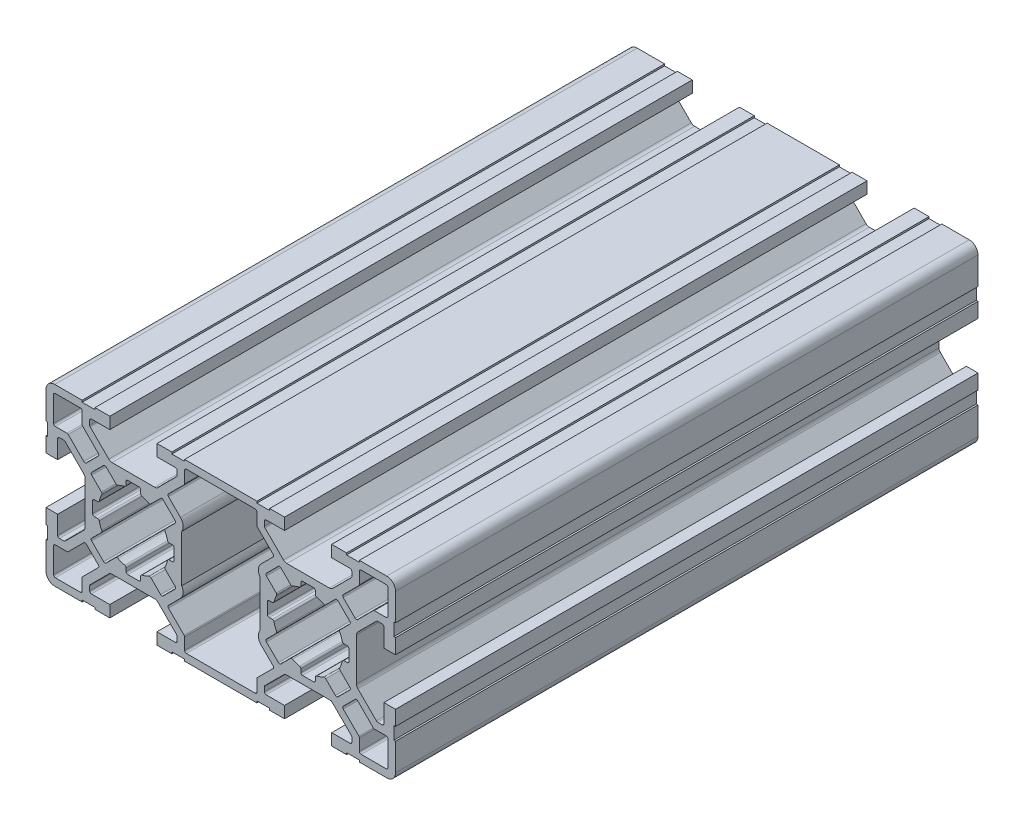
from build123d import *

# Parameters (mm, degrees)
RETANGULAR_PF30_02_PERFIL_3060_B_SICO_DEPTH = 100


with BuildPart() as part:
    # Sketch1 → Retangular PF30-02 - PERFIL 3060 BÁSICO(1) (new body)
    with BuildSketch(Plane(origin=(0, 0, 50), x_dir=(0, -1, 0), z_dir=(0, 0, -1))):
        with BuildLine():
            Line((-4.049998685, 29.999996087), (-4.049998685, 27.999995534))
            Line((-4.049998685, 27.999995534), (-7.199996435, 27.999995648))
            ThreePointArc((-7.199996435, 27.999995648), (-7.412128477, 27.912127686), (-7.499996446, 27.699995648))
            Line((-7.499996446, 27.699995648), (-7.499996446, 26.937612154))
            ThreePointArc((-7.499996446, 26.937612154), (-7.477160306, 26.822807125), (-7.412128481, 26.72548012))
            Line((-7.412128481, 26.72548012), (-4.22098228, 23.53433392))
            ThreePointArc((-4.22098228, 23.53433392), (-3.961443601, 23.360915719), (-3.655296856, 23.300019345))
            Line((-3.655296856, 23.300019345), (3.655296879, 23.300019345))
            ThreePointArc((3.655296879, 23.300019345), (3.961443625, 23.360915719), (4.220982304, 23.53433392))
            Line((4.220982304, 23.53433392), (7.412128505, 26.72548012))
            ThreePointArc((7.412128505, 26.72548012), (7.47716033, 26.822807125), (7.49999647, 26.937612154))
            Line((7.49999647, 26.937612154), (7.49999647, 27.699995534))
            ThreePointArc((7.49999647, 27.699995534), (7.412128505, 27.912127568), (7.19999647, 27.999995534))
            Line((7.19999647, 27.999995534), (4.05, 27.999995534))
            Line((4.05, 27.999995534), (4.05, 29.999996185))
            Line((4.05, 29.999996185), (6.599996803, 29.999996185))
            Line((6.599996803, 29.999996185), (6.599996803, 29.699996185))
            Line((6.599996803, 29.699996185), (8.799996803, 29.699996185))
            Line((8.799996803, 29.699996185), (8.799996803, 29.999996087))
            Line((8.799996803, 29.999996087), (13.499995923, 29.999996087))
            ThreePointArc((13.499995923, 29.999996087), (14.560656066, 29.560656231), (14.999995923, 28.499996087))
            Line((14.999995923, 28.499996087), (14.999995923, 23.799996967))
            Line((14.999995923, 23.799996967), (14.699995923, 23.799996967))
            Line((14.699995923, 23.799996967), (14.699995923, 21.599996967))
            Line((14.699995923, 21.599996967), (14.999995923, 21.599996967))
            Line((14.999995923, 21.599996967), (14.999995923, 19.04999885))
            Line((14.999995923, 19.04999885), (12.999995369, 19.04999885))
            Line((12.999995369, 19.04999885), (12.999995483, 22.1999966))
            ThreePointArc((12.999995483, 22.1999966), (12.912127522, 22.412128642), (12.699995483, 22.499996611))
            Line((12.699995483, 22.499996611), (11.93761199, 22.499996611))
            ThreePointArc((11.93761199, 22.499996611), (11.82280696, 22.477160471), (11.725479955, 22.412128645))
            Line((11.725479955, 22.412128645), (8.534333755, 19.220982445))
            ThreePointArc((8.534333755, 19.220982445), (8.360915554, 18.961443766), (8.30001918, 18.65529702))
            Line((8.30001918, 18.65529702), (8.30001918, 11.344703285))
            ThreePointArc((8.30001918, 11.344703285), (8.360915554, 11.038556539), (8.534333755, 10.77901786))
            Line((8.534333755, 10.77901786), (11.725479955, 7.58787166))
            ThreePointArc((11.725479955, 7.58787166), (11.82280696, 7.522839835), (11.93761199, 7.500003694))
            Line((11.93761199, 7.500003694), (12.699995369, 7.500003694))
            ThreePointArc((12.699995369, 7.500003694), (12.912127403, 7.58787166), (12.999995369, 7.800003694))
            Line((12.999995369, 7.800003694), (12.999995369, 10.950000165))
            Line((12.999995369, 10.950000165), (14.99999602, 10.950000165))
            Line((14.99999602, 10.950000165), (14.99999602, 8.400003362))
            Line((14.99999602, 8.400003362), (14.69999602, 8.400003362))
            Line((14.69999602, 8.400003362), (14.69999602, 6.200003362))
            Line((14.69999602, 6.200003362), (14.99999602, 6.200003362))
            Line((14.99999602, 6.200003362), (14.99999602, -6.200003033))
            Line((14.99999602, -6.200003033), (14.69999602, -6.200003033))
            Line((14.69999602, -6.200003033), (14.69999602, -8.400003033))
            Line((14.69999602, -8.400003033), (14.99999602, -8.400003033))
            Line((14.99999602, -8.400003033), (14.99999602, -10.949999835))
            Line((14.99999602, -10.949999835), (12.999995369, -10.949999835))
            Line((12.999995369, -10.949999835), (12.999995369, -7.800003365))
            ThreePointArc((12.999995369, -7.800003365), (12.912127403, -7.587871331), (12.699995369, -7.500003365))
            Line((12.699995369, -7.500003365), (11.93761199, -7.500003365))
            ThreePointArc((11.93761199, -7.500003365), (11.82280696, -7.522839505), (11.725479955, -7.587871331))
            Line((11.725479955, -7.587871331), (8.534333755, -10.779017531))
            ThreePointArc((8.534333755, -10.779017531), (8.360915554, -11.03855621), (8.30001918, -11.344702956))
            Line((8.30001918, -11.344702956), (8.30001918, -18.655296691))
            ThreePointArc((8.30001918, -18.655296691), (8.360915554, -18.961443437), (8.534333755, -19.220982116))
            Line((8.534333755, -19.220982116), (11.725479955, -22.412128316))
            ThreePointArc((11.725479955, -22.412128316), (11.82280696, -22.477160141), (11.93761199, -22.499996282))
            Line((11.93761199, -22.499996282), (12.699995483, -22.499996282))
            ThreePointArc((12.699995483, -22.499996282), (12.912127522, -22.412128312), (12.999995483, -22.199996271))
            Line((12.999995483, -22.199996271), (12.999995369, -19.04999852))
            Line((12.999995369, -19.04999852), (14.999995923, -19.04999852))
            Line((14.999995923, -19.04999852), (14.999995923, -21.599996638))
            Line((14.999995923, -21.599996638), (14.699995923, -21.599996638))
            Line((14.699995923, -21.599996638), (14.699995923, -23.799996638))
            Line((14.699995923, -23.799996638), (14.999995923, -23.799996638))
            Line((14.999995923, -23.799996638), (14.999995923, -28.499995758))
            ThreePointArc((14.999995923, -28.499995758), (14.560656066, -29.560655901), (13.499995923, -29.999995758))
            Line((13.499995923, -29.999995758), (8.799996803, -29.999995758))
            Line((8.799996803, -29.999995758), (8.799996803, -29.699995855))
            Line((8.799996803, -29.699995855), (6.599996803, -29.699995855))
            Line((6.599996803, -29.699995855), (6.599996803, -29.999995855))
            Line((6.599996803, -29.999995855), (4.05, -29.999995855))
            Line((4.05, -29.999995855), (4.05, -27.999995204))
            Line((4.05, -27.999995204), (7.19999647, -27.999995204))
            ThreePointArc((7.19999647, -27.999995204), (7.412128505, -27.912127239), (7.49999647, -27.699995204))
            Line((7.49999647, -27.699995204), (7.49999647, -26.937611825))
            ThreePointArc((7.49999647, -26.937611825), (7.47716033, -26.822806795), (7.412128505, -26.72547979))
            Line((7.412128505, -26.72547979), (4.220982304, -23.53433359))
            ThreePointArc((4.220982304, -23.53433359), (3.961443625, -23.360915389), (3.655296879, -23.300019015))
            Line((3.655296879, -23.300019015), (-3.655296856, -23.300019015))
            ThreePointArc((-3.655296856, -23.300019015), (-3.961443601, -23.360915389), (-4.22098228, -23.53433359))
            Line((-4.22098228, -23.53433359), (-7.412128481, -26.72547979))
            ThreePointArc((-7.412128481, -26.72547979), (-7.477160306, -26.822806795), (-7.499996446, -26.937611825))
            Line((-7.499996446, -26.937611825), (-7.499996446, -27.699995319))
            ThreePointArc((-7.499996446, -27.699995319), (-7.412128477, -27.912127357), (-7.199996435, -27.999995319))
            Line((-7.199996435, -27.999995319), (-4.049998685, -27.999995204))
            Line((-4.049998685, -27.999995204), (-4.049998685, -29.999995758))
            Line((-4.049998685, -29.999995758), (-6.599996803, -29.999995758))
            Line((-6.599996803, -29.999995758), (-6.599996803, -29.699995758))
            Line((-6.599996803, -29.699995758), (-8.799996803, -29.699995758))
            Line((-8.799996803, -29.699995758), (-8.799996803, -29.999995758))
            Line((-8.799996803, -29.999995758), (-13.499995923, -29.999995758))
            ThreePointArc((-13.499995923, -29.999995758), (-14.560656066, -29.560655901), (-14.999995923, -28.499995758))
            Line((-14.999995923, -28.499995758), (-14.999995923, -23.799996638))
            Line((-14.999995923, -23.799996638), (-14.699995923, -23.799996638))
            Line((-14.699995923, -23.799996638), (-14.699995923, -21.599996638))
            Line((-14.699995923, -21.599996638), (-14.999995923, -21.599996638))
            Line((-14.999995923, -21.599996638), (-14.999995923, -19.04999852))
            Line((-14.999995923, -19.04999852), (-12.999995369, -19.04999852))
            Line((-12.999995369, -19.04999852), (-12.999995483, -22.199996271))
            ThreePointArc((-12.999995483, -22.199996271), (-12.912127522, -22.412128312), (-12.699995483, -22.499996282))
            Line((-12.699995483, -22.499996282), (-11.93761199, -22.499996282))
            ThreePointArc((-11.93761199, -22.499996282), (-11.82280696, -22.477160141), (-11.725479955, -22.412128316))
            Line((-11.725479955, -22.412128316), (-8.534333755, -19.220982116))
            ThreePointArc((-8.534333755, -19.220982116), (-8.360915554, -18.961443437), (-8.30001918, -18.655296691))
            Line((-8.30001918, -18.655296691), (-8.30001918, -11.344702956))
            ThreePointArc((-8.30001918, -11.344702956), (-8.360915554, -11.03855621), (-8.534333755, -10.779017531))
            Line((-8.534333755, -10.779017531), (-11.725479955, -7.587871331))
            ThreePointArc((-11.725479955, -7.587871331), (-11.82280696, -7.522839505), (-11.93761199, -7.500003365))
            Line((-11.93761199, -7.500003365), (-12.699995369, -7.500003365))
            ThreePointArc((-12.699995369, -7.500003365), (-12.912127403, -7.587871331), (-12.999995369, -7.800003365))
            Line((-12.999995369, -7.800003365), (-12.999995369, -10.949999835))
            Line((-12.999995369, -10.949999835), (-14.99999602, -10.949999835))
            Line((-14.99999602, -10.949999835), (-14.99999602, -8.400003033))
            Line((-14.99999602, -8.400003033), (-14.69999602, -8.400003033))
            Line((-14.69999602, -8.400003033), (-14.69999602, -6.200003033))
            Line((-14.69999602, -6.200003033), (-14.99999602, -6.200003033))
            Line((-14.99999602, -6.200003033), (-14.99999602, 6.200003362))
            Line((-14.99999602, 6.200003362), (-14.69999602, 6.200003362))
            Line((-14.69999602, 6.200003362), (-14.69999602, 8.400003362))
            Line((-14.69999602, 8.400003362), (-14.99999602, 8.400003362))
            Line((-14.99999602, 8.400003362), (-14.99999602, 10.950000165))
            Line((-14.99999602, 10.950000165), (-12.999995369, 10.950000165))
            Line((-12.999995369, 10.950000165), (-12.999995369, 7.800003694))
            ThreePointArc((-12.999995369, 7.800003694), (-12.912127403, 7.58787166), (-12.699995369, 7.500003694))
            Line((-12.699995369, 7.500003694), (-11.93761199, 7.500003694))
            ThreePointArc((-11.93761199, 7.500003694), (-11.82280696, 7.522839835), (-11.725479955, 7.58787166))
            Line((-11.725479955, 7.58787166), (-8.534333755, 10.77901786))
            ThreePointArc((-8.534333755, 10.77901786), (-8.360915554, 11.038556539), (-8.30001918, 11.344703285))
            Line((-8.30001918, 11.344703285), (-8.30001918, 18.65529702))
            ThreePointArc((-8.30001918, 18.65529702), (-8.360915554, 18.961443766), (-8.534333755, 19.220982445))
            Line((-8.534333755, 19.220982445), (-11.725479955, 22.412128645))
            ThreePointArc((-11.725479955, 22.412128645), (-11.82280696, 22.477160471), (-11.93761199, 22.499996611))
            Line((-11.93761199, 22.499996611), (-12.699995483, 22.499996611))
            ThreePointArc((-12.699995483, 22.499996611), (-12.912127522, 22.412128642), (-12.999995483, 22.1999966))
            Line((-12.999995483, 22.1999966), (-12.999995369, 19.04999885))
            Line((-12.999995369, 19.04999885), (-14.999995923, 19.04999885))
            Line((-14.999995923, 19.04999885), (-14.999995923, 21.599996967))
            Line((-14.999995923, 21.599996967), (-14.699995923, 21.599996967))
            Line((-14.699995923, 21.599996967), (-14.699995923, 23.799996967))
            Line((-14.699995923, 23.799996967), (-14.999995923, 23.799996967))
            Line((-14.999995923, 23.799996967), (-14.999995923, 28.499996087))
            ThreePointArc((-14.999995923, 28.499996087), (-14.560656066, 29.560656231), (-13.499995923, 29.999996087))
            Line((-13.499995923, 29.999996087), (-8.799996803, 29.999996087))
            Line((-8.799996803, 29.999996087), (-8.799996803, 29.699996087))
            Line((-8.799996803, 29.699996087), (-6.599996803, 29.699996087))
            Line((-6.599996803, 29.699996087), (-6.599996803, 29.999996087))
            Line((-6.599996803, 29.999996087), (-4.049998685, 29.999996087))
        make_face()
        with BuildLine():
            Line((-6.025843274, -23.500716843), (-8.712128837, -26.187002406))
            ThreePointArc((-8.712128837, -26.187002406), (-8.777160662, -26.284329411), (-8.799996803, -26.399134441))
            Line((-8.799996803, -26.399134441), (-8.799996803, -28.399996053))
            ThreePointArc((-8.799996803, -28.399996053), (-8.887864768, -28.612128088), (-9.099996803, -28.699996053))
            Line((-9.099996803, -28.699996053), (-13.399996218, -28.699996053))
            ThreePointArc((-13.399996218, -28.699996053), (-13.612128252, -28.612128088), (-13.699996218, -28.399996053))
            Line((-13.699996218, -28.399996053), (-13.699996218, -24.09999627))
            ThreePointArc((-13.699996218, -24.09999627), (-13.612128251, -23.887864234), (-13.399996213, -23.79999627))
            Line((-13.399996213, -23.79999627), (-11.39913459, -23.79999627))
            ThreePointArc((-11.39913459, -23.79999627), (-11.28432956, -23.777160132), (-11.187002554, -23.712128308))
            Line((-11.187002554, -23.712128308), (-8.50071665, -21.025842489))
            ThreePointArc((-8.50071665, -21.025842489), (-8.288584582, -20.937974527), (-8.076452536, -21.025842541))
            Line((-8.076452536, -21.025842541), (-6.025843225, -23.076452792))
            ThreePointArc((-6.025843225, -23.076452792), (-5.937975293, -23.288584828), (-6.025843274, -23.500716843))
        make_face(mode=Mode.SUBTRACT)
        with BuildLine():
            Line((13.699995411, 5.900003245), (13.699995411, -5.900003245))
            ThreePointArc((13.699995411, -5.900003245), (13.612127462, -6.112135263), (13.399995459, -6.200003245))
            Line((13.399995459, -6.200003245), (11.399134078, -6.200003565))
            ThreePointArc((11.399134078, -6.200003565), (11.284329048, -6.222839703), (11.187002043, -6.287871527))
            Line((11.187002043, -6.287871527), (8.500716138, -8.974157346))
            ThreePointArc((8.500716138, -8.974157346), (8.288584071, -9.062025309), (8.076452024, -8.974157294))
            Line((8.076452024, -8.974157294), (6.025842487, -6.923546817))
            ThreePointArc((6.025842487, -6.923546817), (5.073763999, -6.46499579), (4.043474958, -6.700000009))
            Line((4.043474958, -6.700000009), (-4.043474611, -6.700000009))
            ThreePointArc((-4.043474611, -6.700000009), (-5.073763999, -6.464995655), (-6.025842825, -6.923546826))
            Line((-6.025842825, -6.923546826), (-8.076452363, -8.974157303))
            ThreePointArc((-8.076452363, -8.974157303), (-8.288584409, -9.062025317), (-8.500716477, -8.974157355))
            Line((-8.500716477, -8.974157355), (-11.187002381, -6.287871536))
            ThreePointArc((-11.187002381, -6.287871536), (-11.284329387, -6.222839712), (-11.399134417, -6.200003574))
            Line((-11.399134417, -6.200003574), (-13.399995797, -6.200003254))
            ThreePointArc((-13.399995797, -6.200003254), (-13.6121278, -6.112135271), (-13.699995749, -5.900003254))
            Line((-13.699995749, -5.900003254), (-13.699995749, 5.900003237))
            ThreePointArc((-13.699995749, 5.900003237), (-13.6121278, 6.112135254), (-13.399995797, 6.200003237))
            Line((-13.399995797, 6.200003237), (-11.399134417, 6.200003556))
            ThreePointArc((-11.399134417, 6.200003556), (-11.284329387, 6.222839695), (-11.187002381, 6.287871518))
            Line((-11.187002381, 6.287871518), (-8.500716477, 8.974157338))
            ThreePointArc((-8.500716477, 8.974157338), (-8.288584409, 9.0620253), (-8.076452363, 8.974157286))
            Line((-8.076452363, 8.974157286), (-6.025842825, 6.923546808))
            ThreePointArc((-6.025842825, 6.923546808), (-5.073763999, 6.464995638), (-4.043474611, 6.699999991))
            Line((-4.043474611, 6.699999991), (4.043474958, 6.699999991))
            ThreePointArc((4.043474958, 6.699999991), (5.073764124, 6.464995837), (6.025842695, 6.923546939))
            Line((6.025842695, 6.923546939), (8.076452232, 8.974157416))
            ThreePointArc((8.076452232, 8.974157416), (8.288584278, 9.06202543), (8.500716346, 8.974157468))
            Line((8.500716346, 8.974157468), (11.18700225, 6.287871649))
            ThreePointArc((11.18700225, 6.287871649), (11.284329256, 6.222839825), (11.399134286, 6.200003687))
            Line((11.399134286, 6.200003687), (13.399995667, 6.200003367))
            ThreePointArc((13.399995667, 6.200003367), (13.612127579, 6.112135268), (13.699995411, 5.900003245))
        make_face(mode=Mode.SUBTRACT)
        with BuildLine():
            Line((8.076452536, 21.02584287), (6.025843225, 23.076453121))
            ThreePointArc((6.025843225, 23.076453121), (5.937975293, 23.288585157), (6.025843274, 23.500717173))
            Line((6.025843274, 23.500717173), (8.712128837, 26.187002736))
            ThreePointArc((8.712128837, 26.187002736), (8.777160662, 26.284329741), (8.799996803, 26.39913477))
            Line((8.799996803, 26.39913477), (8.799996803, 28.399996383))
            ThreePointArc((8.799996803, 28.399996383), (8.887864768, 28.612128417), (9.099996803, 28.699996383))
            Line((9.099996803, 28.699996383), (13.399996218, 28.699996383))
            ThreePointArc((13.399996218, 28.699996383), (13.612128252, 28.612128417), (13.699996218, 28.399996383))
            Line((13.699996218, 28.399996383), (13.699996218, 24.0999966))
            ThreePointArc((13.699996218, 24.0999966), (13.612128251, 23.887864564), (13.399996213, 23.7999966))
            Line((13.399996213, 23.7999966), (11.39913459, 23.7999966))
            ThreePointArc((11.39913459, 23.7999966), (11.28432956, 23.777160461), (11.187002554, 23.712128638))
            Line((11.187002554, 23.712128638), (8.50071665, 21.025842818))
            ThreePointArc((8.50071665, 21.025842818), (8.288584582, 20.937974856), (8.076452536, 21.02584287))
        make_face(mode=Mode.SUBTRACT)
        with BuildLine():
            Line((-8.712128837, 26.187002736), (-6.025843274, 23.500717173))
            ThreePointArc((-6.025843274, 23.500717173), (-5.937975293, 23.288585157), (-6.025843225, 23.076453121))
            Line((-6.025843225, 23.076453121), (-8.076452536, 21.02584287))
            ThreePointArc((-8.076452536, 21.02584287), (-8.288584582, 20.937974856), (-8.50071665, 21.025842818))
            Line((-8.50071665, 21.025842818), (-11.187002554, 23.712128638))
            ThreePointArc((-11.187002554, 23.712128638), (-11.28432956, 23.777160461), (-11.39913459, 23.7999966))
            Line((-11.39913459, 23.7999966), (-13.399996213, 23.7999966))
            ThreePointArc((-13.399996213, 23.7999966), (-13.612128251, 23.887864564), (-13.699996218, 24.0999966))
            Line((-13.699996218, 24.0999966), (-13.699996218, 28.399996383))
            ThreePointArc((-13.699996218, 28.399996383), (-13.612128252, 28.612128417), (-13.399996218, 28.699996383))
            Line((-13.399996218, 28.699996383), (-9.099996803, 28.699996383))
            ThreePointArc((-9.099996803, 28.699996383), (-8.887864768, 28.612128417), (-8.799996803, 28.399996383))
            Line((-8.799996803, 28.399996383), (-8.799996803, 26.39913477))
            ThreePointArc((-8.799996803, 26.39913477), (-8.777160662, 26.284329741), (-8.712128837, 26.187002736))
        make_face(mode=Mode.SUBTRACT)
        with BuildLine():
            Line((-3.012269005, 9.512857426), (-4.68233992, 7.842786511))
            ThreePointArc((-4.68233992, 7.842786511), (-4.894471848, 7.754918817), (-5.10660394, 7.842786115))
            Line((-5.10660394, 7.842786115), (-7.157214075, 9.893395311))
            ThreePointArc((-7.157214075, 9.893395311), (-7.245082089, 10.105527359), (-7.157214124, 10.317659428))
            Line((-7.157214124, 10.317659428), (-5.487142739, 11.987730813))
            ThreePointArc((-5.487142739, 11.987730813), (-5.403317864, 12.15077611), (-5.430017698, 12.332152783))
            ThreePointArc((-5.430017698, 12.332152783), (-5.679814912, 12.916204489), (-5.86699644, 13.523228474))
            ThreePointArc((-5.86699644, 13.523228474), (-5.973488289, 13.686610043), (-6.157921876, 13.750000127))
            Line((-6.157921876, 13.750000127), (-6.700000148, 13.750000127))
            ThreePointArc((-6.700000148, 13.750000127), (-6.912132183, 13.837868093), (-7.000000148, 14.050000127))
            Line((-7.000000148, 14.050000127), (-7.000000148, 15.950000127))
            ThreePointArc((-7.000000148, 15.950000127), (-6.912132183, 16.162132162), (-6.700000148, 16.250000127))
            Line((-6.700000148, 16.250000127), (-6.157921876, 16.250000127))
            ThreePointArc((-6.157921876, 16.250000127), (-5.973488289, 16.313390212), (-5.86699644, 16.476771781))
            ThreePointArc((-5.86699644, 16.476771781), (-5.679814961, 17.083795655), (-5.430017819, 17.667847259))
            ThreePointArc((-5.430017819, 17.667847259), (-5.403317985, 17.849223932), (-5.48714286, 18.012269229))
            Line((-5.48714286, 18.012269229), (-7.157213775, 19.682340144))
            ThreePointArc((-7.157213775, 19.682340144), (-7.245081741, 19.894472144), (-7.157213823, 20.106604164))
            Line((-7.157213823, 20.106604164), (-5.106604628, 22.157214299))
            ThreePointArc((-5.106604628, 22.157214299), (-4.894472579, 22.245082314), (-4.682340511, 22.157214348))
            Line((-4.682340511, 22.157214348), (-3.012269126, 20.487142963))
            ThreePointArc((-3.012269126, 20.487142963), (-2.849223829, 20.403318088), (-2.667847156, 20.430017922))
            ThreePointArc((-2.667847156, 20.430017922), (-2.083795553, 20.679815072), (-1.47677168, 20.86699656))
            ThreePointArc((-1.47677168, 20.86699656), (-1.313390111, 20.973488409), (-1.250000026, 21.157921996))
            Line((-1.250000026, 21.157921996), (-1.250000026, 21.700000268))
            ThreePointArc((-1.250000026, 21.700000268), (-1.16213206, 21.912132303), (-0.950000026, 22.000000268))
            Line((-0.950000026, 22.000000268), (0.949999974, 22.000000268))
            ThreePointArc((0.949999974, 22.000000268), (1.162132008, 21.912132303), (1.249999974, 21.700000268))
            Line((1.249999974, 21.700000268), (1.249999974, 21.157921996))
            ThreePointArc((1.249999974, 21.157921996), (1.313390037, 20.973488339), (1.476771654, 20.866996456))
            ThreePointArc((1.476771654, 20.866996456), (2.083795477, 20.679814986), (2.667847035, 20.430017862))
            ThreePointArc((2.667847035, 20.430017862), (2.849223708, 20.403318029), (3.012269005, 20.487142904))
            Line((3.012269005, 20.487142904), (4.68234039, 22.157214289))
            ThreePointArc((4.68234039, 22.157214289), (4.894472459, 22.245082254), (5.106604507, 22.15721424))
            Line((5.106604507, 22.15721424), (7.157213703, 20.106604105))
            ThreePointArc((7.157213703, 20.106604105), (7.24508162, 19.894472084), (7.157213654, 19.682340084))
            Line((7.157213654, 19.682340084), (5.487142739, 18.01226917))
            ThreePointArc((5.487142739, 18.01226917), (5.403317864, 17.849223873), (5.430017698, 17.6678472))
            ThreePointArc((5.430017698, 17.6678472), (5.679814822, 17.083795642), (5.866996291, 16.476771818))
            ThreePointArc((5.866996291, 16.476771818), (5.97348814, 16.31339025), (6.157921727, 16.250000165))
            Line((6.157921727, 16.250000165), (6.7, 16.250000165))
            ThreePointArc((6.7, 16.250000165), (6.912132034, 16.162132199), (7, 15.950000165))
            Line((7, 15.950000165), (7, 14.050000165))
            ThreePointArc((7, 14.050000165), (6.912132034, 13.83786813), (6.7, 13.750000165))
            Line((6.7, 13.750000165), (6.157921727, 13.750000165))
            ThreePointArc((6.157921727, 13.750000165), (5.97348814, 13.68661008), (5.866996291, 13.523228511))
            ThreePointArc((5.866996291, 13.523228511), (5.679814822, 12.916204687), (5.430017698, 12.33215313))
            ThreePointArc((5.430017698, 12.33215313), (5.403317864, 12.150776457), (5.487142739, 11.98773116))
            Line((5.487142739, 11.98773116), (7.157214124, 10.317659775))
            ThreePointArc((7.157214124, 10.317659775), (7.245082263, 10.105527533), (7.157214075, 9.893395311))
            Line((7.157214075, 9.893395311), (5.10660394, 7.842786115))
            ThreePointArc((5.10660394, 7.842786115), (4.894471848, 7.754918817), (4.68233992, 7.842786511))
            Line((4.68233992, 7.842786511), (3.012269005, 9.512857426))
            ThreePointArc((3.012269005, 9.512857426), (2.849223708, 9.596682301), (2.667847035, 9.569982467))
            ThreePointArc((2.667847035, 9.569982467), (2.083795477, 9.320185343), (1.476771653, 9.133003873))
            ThreePointArc((1.476771653, 9.133003873), (1.313390085, 9.026512025), (1.25, 8.842078437))
            Line((1.25, 8.842078437), (1.25, 8.300000165))
            ThreePointArc((1.25, 8.300000165), (1.162132034, 8.08786813), (0.95, 8.000000165))
            Line((0.95, 8.000000165), (-0.95, 8.000000165))
            ThreePointArc((-0.95, 8.000000165), (-1.162132034, 8.08786813), (-1.25, 8.300000165))
            Line((-1.25, 8.300000165), (-1.25, 8.842078437))
            ThreePointArc((-1.25, 8.842078437), (-1.313390085, 9.026512025), (-1.476771653, 9.133003873))
            ThreePointArc((-1.476771653, 9.133003873), (-2.083795477, 9.320185343), (-2.667847035, 9.569982467))
            ThreePointArc((-2.667847035, 9.569982467), (-2.849223708, 9.596682301), (-3.012269005, 9.512857426))
        make_face(mode=Mode.SUBTRACT)
        with BuildLine():
            Line((-1.249999924, -8.84207841), (-1.249999924, -8.300000137))
            ThreePointArc((-1.249999924, -8.300000137), (-1.162131958, -8.087868103), (-0.949999924, -8.000000137))
            Line((-0.949999924, -8.000000137), (0.950000076, -8.000000137))
            ThreePointArc((0.950000076, -8.000000137), (1.16213211, -8.087868103), (1.250000076, -8.300000137))
            Line((1.250000076, -8.300000137), (1.250000076, -8.84207841))
            ThreePointArc((1.250000076, -8.84207841), (1.313390224, -9.026511795), (1.476771653, -9.133003544))
            ThreePointArc((1.476771653, -9.133003544), (2.083795477, -9.320185014), (2.667847035, -9.569982138))
            ThreePointArc((2.667847035, -9.569982138), (2.849223708, -9.596681971), (3.012269005, -9.512857096))
            Line((3.012269005, -9.512857096), (4.68233992, -7.842786181))
            ThreePointArc((4.68233992, -7.842786181), (4.894471848, -7.754918488), (5.10660394, -7.842785786))
            Line((5.10660394, -7.842785786), (7.157214075, -9.893394981))
            ThreePointArc((7.157214075, -9.893394981), (7.245082263, -10.105527203), (7.157214124, -10.317659445))
            Line((7.157214124, -10.317659445), (5.487142739, -11.98773083))
            ThreePointArc((5.487142739, -11.98773083), (5.403317864, -12.150776127), (5.430017698, -12.3321528))
            ThreePointArc((5.430017698, -12.3321528), (5.679814822, -12.916204358), (5.866996291, -13.523228182))
            ThreePointArc((5.866996291, -13.523228182), (5.97348814, -13.68660975), (6.157921727, -13.749999835))
            Line((6.157921727, -13.749999835), (6.7, -13.749999835))
            ThreePointArc((6.7, -13.749999835), (6.912132034, -13.837867801), (7, -14.049999835))
            Line((7, -14.049999835), (7, -15.949999835))
            ThreePointArc((7, -15.949999835), (6.912132034, -16.16213187), (6.7, -16.249999835))
            Line((6.7, -16.249999835), (6.157921727, -16.249999835))
            ThreePointArc((6.157921727, -16.249999835), (5.97348814, -16.31338992), (5.866996291, -16.476771489))
            ThreePointArc((5.866996291, -16.476771489), (5.679814822, -17.083795313), (5.430017698, -17.66784687))
            ThreePointArc((5.430017698, -17.66784687), (5.403317864, -17.849223543), (5.487142739, -18.01226884))
            Line((5.487142739, -18.01226884), (7.157213654, -19.682339755))
            ThreePointArc((7.157213654, -19.682339755), (7.24508162, -19.894471755), (7.157213703, -20.106603775))
            Line((7.157213703, -20.106603775), (5.106604507, -22.157213911))
            ThreePointArc((5.106604507, -22.157213911), (4.894472459, -22.245081925), (4.68234039, -22.157213959))
            Line((4.68234039, -22.157213959), (3.012269005, -20.487142574))
            ThreePointArc((3.012269005, -20.487142574), (2.849223708, -20.403317699), (2.667847035, -20.430017533))
            ThreePointArc((2.667847035, -20.430017533), (2.083795477, -20.679814657), (1.476771654, -20.866996127))
            ThreePointArc((1.476771654, -20.866996127), (1.313390085, -20.973487976), (1.25, -21.157921563))
            Line((1.25, -21.157921563), (1.25, -21.699999835))
            ThreePointArc((1.25, -21.699999835), (1.162132034, -21.91213187), (0.95, -21.999999835))
            Line((0.95, -21.999999835), (-0.95, -21.999999835))
            ThreePointArc((-0.95, -21.999999835), (-1.162132034, -21.91213187), (-1.25, -21.699999835))
            Line((-1.25, -21.699999835), (-1.25, -21.157921563))
            ThreePointArc((-1.25, -21.157921563), (-1.313390085, -20.973487976), (-1.476771654, -20.866996127))
            ThreePointArc((-1.476771654, -20.866996127), (-2.083795477, -20.679814657), (-2.667847035, -20.430017533))
            ThreePointArc((-2.667847035, -20.430017533), (-2.849223708, -20.403317699), (-3.012269005, -20.487142574))
            Line((-3.012269005, -20.487142574), (-4.68234039, -22.157213959))
            ThreePointArc((-4.68234039, -22.157213959), (-4.894472459, -22.245081925), (-5.106604507, -22.157213911))
            Line((-5.106604507, -22.157213911), (-7.157213703, -20.106603775))
            ThreePointArc((-7.157213703, -20.106603775), (-7.24508162, -19.894471755), (-7.157213654, -19.682339755))
            Line((-7.157213654, -19.682339755), (-5.487142739, -18.01226884))
            ThreePointArc((-5.487142739, -18.01226884), (-5.403317864, -17.849223543), (-5.430017698, -17.66784687))
            ThreePointArc((-5.430017698, -17.66784687), (-5.679814822, -17.083795313), (-5.866996291, -16.476771489))
            ThreePointArc((-5.866996291, -16.476771489), (-5.97348814, -16.31338992), (-6.157921727, -16.249999835))
            Line((-6.157921727, -16.249999835), (-6.7, -16.249999835))
            ThreePointArc((-6.7, -16.249999835), (-6.912132034, -16.16213187), (-7, -15.949999835))
            Line((-7, -15.949999835), (-7, -14.049999835))
            ThreePointArc((-7, -14.049999835), (-6.912132034, -13.837867801), (-6.7, -13.749999835))
            Line((-6.7, -13.749999835), (-6.157921727, -13.749999835))
            ThreePointArc((-6.157921727, -13.749999835), (-5.97348814, -13.68660975), (-5.866996291, -13.523228182))
            ThreePointArc((-5.866996291, -13.523228182), (-5.679814822, -12.916204358), (-5.430017698, -12.3321528))
            ThreePointArc((-5.430017698, -12.3321528), (-5.403317864, -12.150776127), (-5.487142739, -11.98773083))
            Line((-5.487142739, -11.98773083), (-7.157214124, -10.317659445))
            ThreePointArc((-7.157214124, -10.317659445), (-7.245082089, -10.105527377), (-7.157214075, -9.893395328))
            Line((-7.157214075, -9.893395328), (-5.10660394, -7.842786133))
            ThreePointArc((-5.10660394, -7.842786133), (-4.894471848, -7.754918835), (-4.68233992, -7.842786528))
            Line((-4.68233992, -7.842786528), (-3.012269005, -9.512857443))
            ThreePointArc((-3.012269005, -9.512857443), (-2.849223708, -9.596682318), (-2.667847035, -9.569982485))
            ThreePointArc((-2.667847035, -9.569982485), (-2.083795442, -9.320185332), (-1.476771577, -9.133003846))
            ThreePointArc((-1.476771577, -9.133003846), (-1.313390009, -9.026511997), (-1.249999924, -8.84207841))
        make_face(mode=Mode.SUBTRACT)
        with BuildLine():
            Line((6.025843225, -23.076452792), (8.076452536, -21.025842541))
            ThreePointArc((8.076452536, -21.025842541), (8.288584582, -20.937974527), (8.50071665, -21.025842489))
            Line((8.50071665, -21.025842489), (11.187002554, -23.712128308))
            ThreePointArc((11.187002554, -23.712128308), (11.28432956, -23.777160132), (11.39913459, -23.79999627))
            Line((11.39913459, -23.79999627), (13.399996213, -23.79999627))
            ThreePointArc((13.399996213, -23.79999627), (13.612128251, -23.887864234), (13.699996218, -24.09999627))
            Line((13.699996218, -24.09999627), (13.699996218, -28.399996053))
            ThreePointArc((13.699996218, -28.399996053), (13.612128252, -28.612128088), (13.399996218, -28.699996053))
            Line((13.399996218, -28.699996053), (9.099996803, -28.699996053))
            ThreePointArc((9.099996803, -28.699996053), (8.887864768, -28.612128088), (8.799996803, -28.399996053))
            Line((8.799996803, -28.399996053), (8.799996803, -26.399134441))
            ThreePointArc((8.799996803, -26.399134441), (8.777160662, -26.284329411), (8.712128837, -26.187002406))
            Line((8.712128837, -26.187002406), (6.025843274, -23.500716843))
            ThreePointArc((6.025843274, -23.500716843), (5.937975293, -23.288584828), (6.025843225, -23.076452792))
        make_face(mode=Mode.SUBTRACT)
    extrude(amount=RETANGULAR_PF30_02_PERFIL_3060_B_SICO_DEPTH)


solid = part.part
